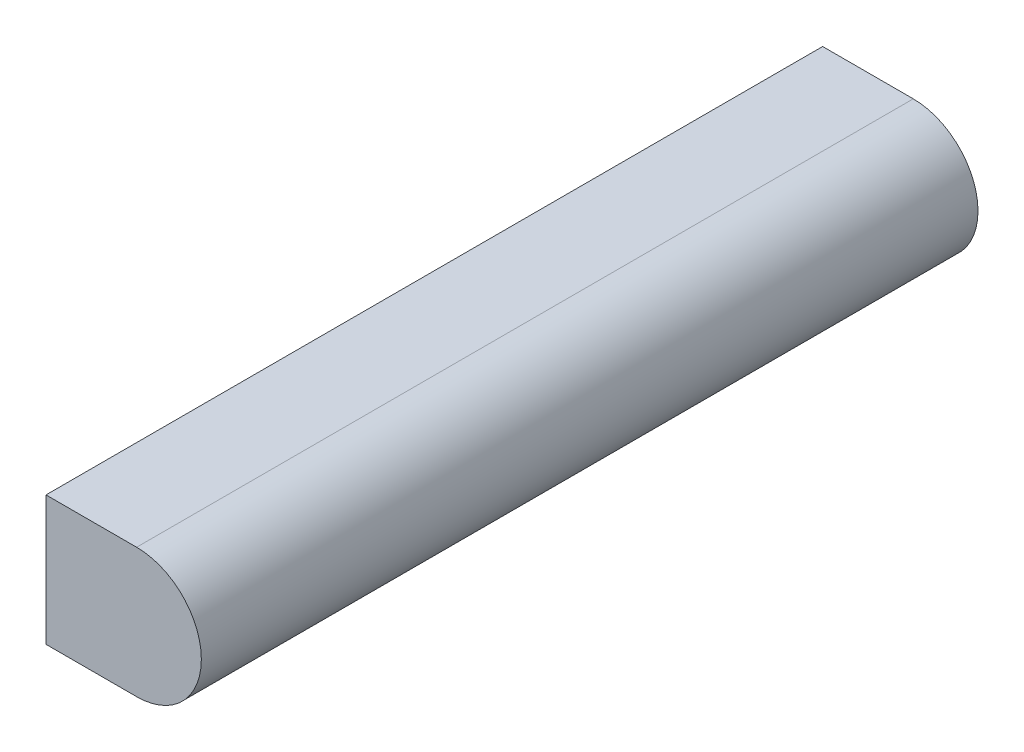
from build123d import *

# Parameters (mm, degrees)
BOSS_EXTRUDE1_DEPTH = 38.1


with BuildPart() as part:
    # Sketch3 → Boss-Extrude1 (new body)
    with BuildSketch(Plane.XY.offset(38.1)):
        with BuildLine():
            Line((3.177, -3.174), (7.621, -3.174))
            ThreePointArc((7.621, -3.174), (10.796, 0.001), (7.621, 3.176))
            Line((7.621, 3.176), (3.175, 3.176))
            Line((3.175, 3.176), (3.177, -3.174))
        make_face()
    extrude(amount=-BOSS_EXTRUDE1_DEPTH)


solid = part.part
